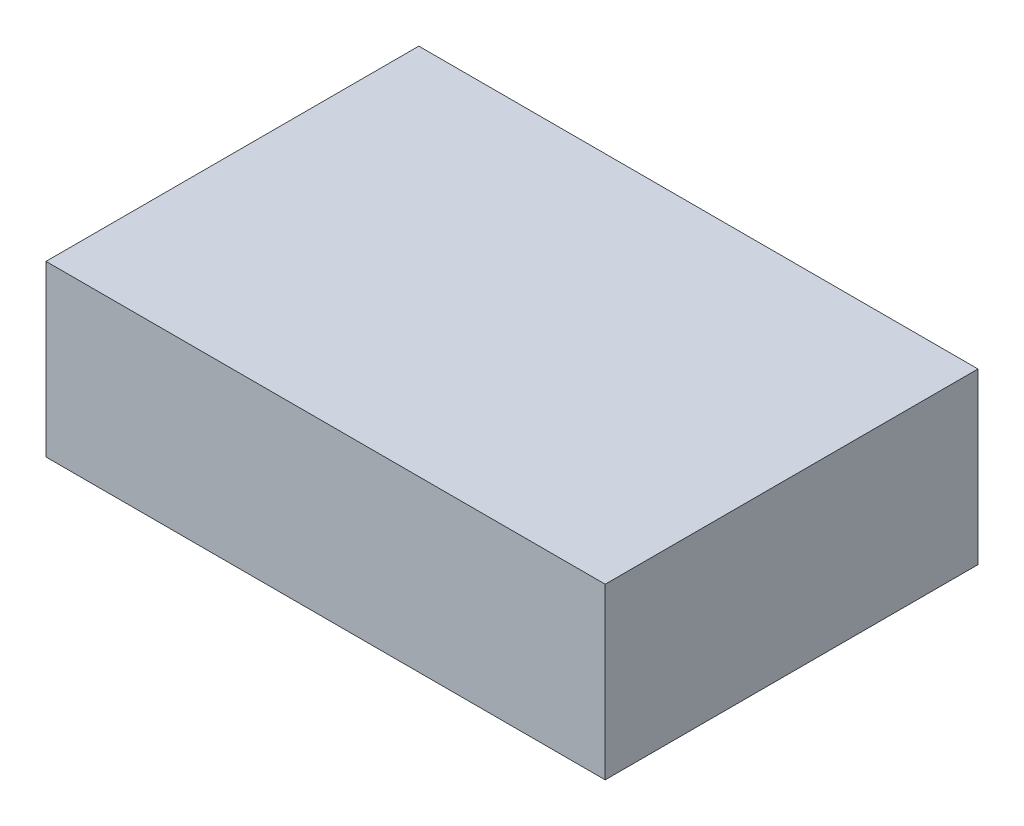
from build123d import *

# Parameters (mm, degrees)
SKETCH1_W           = 66
SKETCH1_H           = 44
BOSS_EXTRUDE1_DEPTH = 20


with BuildPart() as part:
    # Sketch1 → Boss-Extrude1 (new body)
    with BuildSketch(Plane(origin=(0, 0, 0), x_dir=(1, 0, 0), z_dir=(0, 1, 0))):
        Rectangle(SKETCH1_W, SKETCH1_H)
    extrude(amount=BOSS_EXTRUDE1_DEPTH)


solid = part.part
